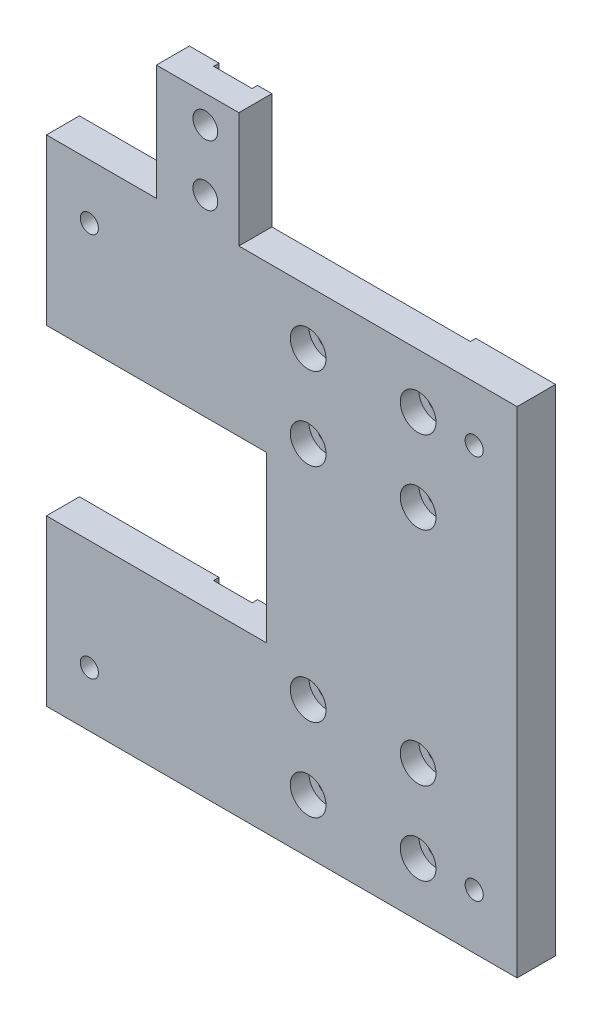
from build123d import *

# Parameters (mm, degrees)
SKETCH_1_W                   = 85.6
SKETCH_1_H                   = 90
EXTRUDE_1_DEPTH              = 6
SKETCH_2_W                   = 40
SKETCH_2_H                   = 30
CUT_EXTRUDE_1_DEPTH          = 7
SKETCH_3_W                   = 14.5
SKETCH_3_H                   = 90
EXTRUDE_2_DEPTH              = 1
HOLE_WIZARD_M3_1_D           = 3.4
HOLE_WIZARD_M3_1_CBORE_D     = 6.5
HOLE_WIZARD_M3_1_CBORE_DEPTH = 3.4
HOLE_WIZARD_M4_1_D           = 3.3
SKETCH_11_W                  = 35
SKETCH_11_H                  = 6
EXTRUDE_3_DEPTH              = 21
SKETCH_12_W                  = 20
SKETCH_12_H                  = 21
CUT_EXTRUDE_3_DEPTH          = 21
SKETCH_14_W                  = 7
SKETCH_14_H                  = 116.324427337
CUT_EXTRUDE_4_DEPTH          = 1
SKETCH_17_R                  = 2.25
CUT_EXTRUDE_5_DEPTH          = 8


with BuildPart() as part:
    # 草图1 → 凸台-拉伸1 (new body)
    with BuildSketch(Plane.XY):
        with Locations((42.8, 45)):
            Rectangle(SKETCH_1_W, SKETCH_1_H)
    extrude(amount=EXTRUDE_1_DEPTH)

    # 草图2 → 切除-拉伸1 (cut, through all)
    with BuildSketch(Plane.XY.offset(6)):
        with Locations((20, 45)):
            Rectangle(SKETCH_2_W, SKETCH_2_H)
    extrude(amount=-CUT_EXTRUDE_1_DEPTH, mode=Mode.SUBTRACT)

    # 草图3 → 凸台-拉伸2 (add)
    with BuildSketch(Plane(origin=(0, 0, 0), x_dir=(-1, 0, 0), z_dir=(0, 0, -1))):
        with Locations((-78.35, 45)):
            Rectangle(SKETCH_3_W, SKETCH_3_H)
    extrude(amount=EXTRUDE_2_DEPTH)

    # M3 六角凹头螺钉的柱形沉头孔1 (through all)
    with Locations(Plane.XY.offset(6)):
        with Locations((67.6, 65.15), (47.6, 65.15), (67.6, 80.15), (47.6, 80.15)):
            hole_wizard_m3_1 = CounterBoreHole(HOLE_WIZARD_M3_1_D / 2, HOLE_WIZARD_M3_1_CBORE_D / 2, HOLE_WIZARD_M3_1_CBORE_DEPTH)

    # 镜向1: M3 六角凹头螺钉的柱形沉头孔1 across plane
    add(hole_wizard_m3_1.mirror(Plane.ZX.offset(45)), mode=Mode.SUBTRACT)

    # M4 螺纹孔1 (through all)
    with Locations(Plane.XY.offset(6)):
        with Locations((77.8, 10), (7.8, 10), (77.8, 80), (7.8, 80)):
            Hole(HOLE_WIZARD_M4_1_D / 2)

    # 草图11 → 凸台-拉伸3 (add)
    with BuildSketch(Plane(origin=(0, 90, 0), x_dir=(1, 0, 0), z_dir=(0, 1, 0))):
        with Locations((17.5, -3)):
            Rectangle(SKETCH_11_W, SKETCH_11_H)
    extrude(amount=EXTRUDE_3_DEPTH)

    # 草图12 → 切除-拉伸3 (cut)
    with BuildSketch(Plane.XY.offset(6)):
        with Locations((10, 100.5)):
            Rectangle(SKETCH_12_W, SKETCH_12_H)
    extrude(amount=-CUT_EXTRUDE_3_DEPTH, mode=Mode.SUBTRACT)

    # 草图14 → 切除-拉伸4 (cut)
    with BuildSketch(Plane(origin=(0, 0, 0), x_dir=(-1, 0, 0), z_dir=(0, 0, -1))):
        with Locations((-28.9, 52.837786331)):
            Rectangle(SKETCH_14_W, SKETCH_14_H)
    extrude(amount=-CUT_EXTRUDE_4_DEPTH, mode=Mode.SUBTRACT)

    # 草图17 → 切除-拉伸5 (cut, through all)
    with BuildSketch(Plane.XY.offset(6)):
        with Locations((28.9, 106)):
            Circle(SKETCH_17_R)
        with Locations((28.9, 95)):
            Circle(SKETCH_17_R)
    extrude(amount=-CUT_EXTRUDE_5_DEPTH, mode=Mode.SUBTRACT)


solid = part.part
